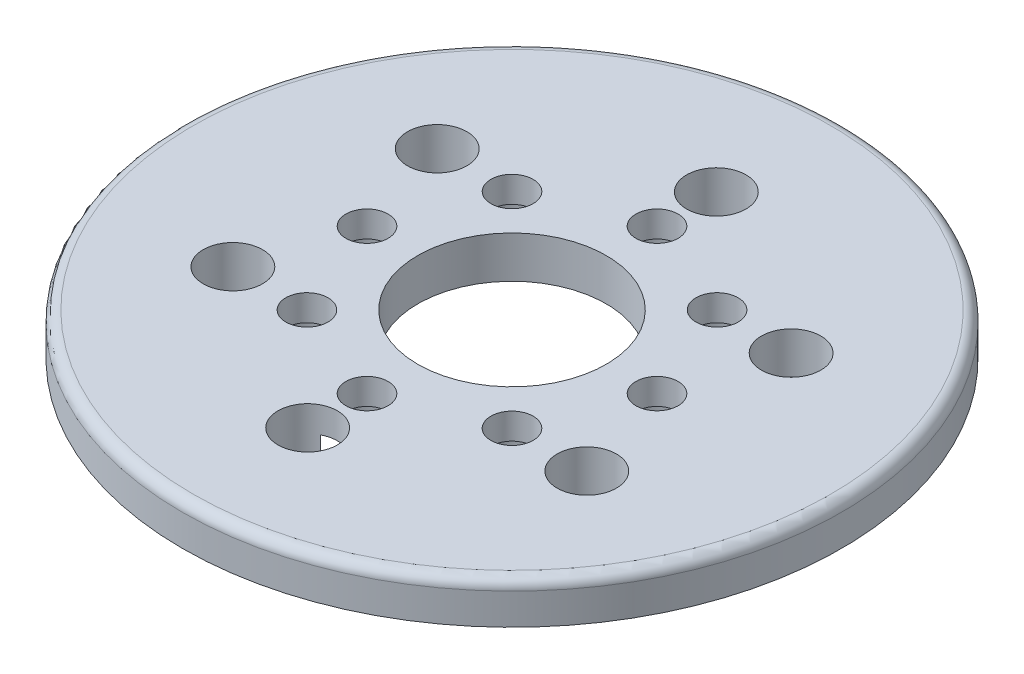
from build123d import *

# Parameters (mm, degrees)
SKETCH1_R           = 25
SKETCH1_R_2         = 7.15
BOSS_EXTRUDE1_DEPTH = 3.175
SKETCH2_R           = 2.25
CUT_EXTRUDE1_DEPTH  = 4.175
CIRPATTERN1_COUNT   = 6
SKETCH4_R           = 1.6
CUT_EXTRUDE3_DEPTH  = 4.175
SKETCH5_R           = 2.7
CUT_EXTRUDE4_DEPTH  = 1.2
CIRPATTERN3_COUNT   = 8
FILLET1_R           = 0.8


with BuildPart() as part:
    # Sketch1 → Boss-Extrude1 (new body)
    with BuildSketch(Plane(origin=(0, 0, 0), x_dir=(1, 0, 0), z_dir=(0, 1, 0))):
        Circle(SKETCH1_R)
        Circle(SKETCH1_R_2, mode=Mode.SUBTRACT)
    extrude(amount=BOSS_EXTRUDE1_DEPTH)

    # Sketch2 → Cut-Extrude1 (cut, through all)
    with BuildSketch(Plane(origin=(0, 3.175, 0), x_dir=(1, 0, 0), z_dir=(0, 1, 0))):
        with Locations((0, 15.5)):
            Circle(SKETCH2_R)
    cut_extrude1 = extrude(amount=-CUT_EXTRUDE1_DEPTH, mode=Mode.SUBTRACT)

    # CirPattern1: Cut-Extrude1 ×6 about axis
    cirpattern1_axis = Axis((0, 0, 0), (0, 1, 0))
    for i in range(1, CIRPATTERN1_COUNT):
        add(cut_extrude1.rotate(cirpattern1_axis, i * 360 / CIRPATTERN1_COUNT), mode=Mode.SUBTRACT)

    # Sketch4 → Cut-Extrude3 (cut, through all)
    with BuildSketch(Plane.XZ):
        with Locations((0, 11)):
            Circle(SKETCH4_R)
    cut_extrude3 = extrude(amount=-CUT_EXTRUDE3_DEPTH, mode=Mode.SUBTRACT)

    # Sketch5 → Cut-Extrude4 (cut)
    with BuildSketch(Plane.XZ):
        with Locations((0, 11)):
            Circle(SKETCH5_R)
    cut_extrude4 = extrude(amount=-CUT_EXTRUDE4_DEPTH, mode=Mode.SUBTRACT)

    # CirPattern3: Cut-Extrude3, Cut-Extrude4 ×8 about axis
    cirpattern3_axis = Axis((0, 0, 0), (0, 1, 0))
    for i in range(1, CIRPATTERN3_COUNT):
        add(cut_extrude3.rotate(cirpattern3_axis, i * 360 / CIRPATTERN3_COUNT), mode=Mode.SUBTRACT)
        add(cut_extrude4.rotate(cirpattern3_axis, i * 360 / CIRPATTERN3_COUNT), mode=Mode.SUBTRACT)

    # Fillet1
    fillet1_edges = [part.edges().sort_by_distance(p)[0] for p in [
        (-25, 3.175, 0),
    ]]
    fillet(fillet1_edges, radius=FILLET1_R)


solid = part.part
